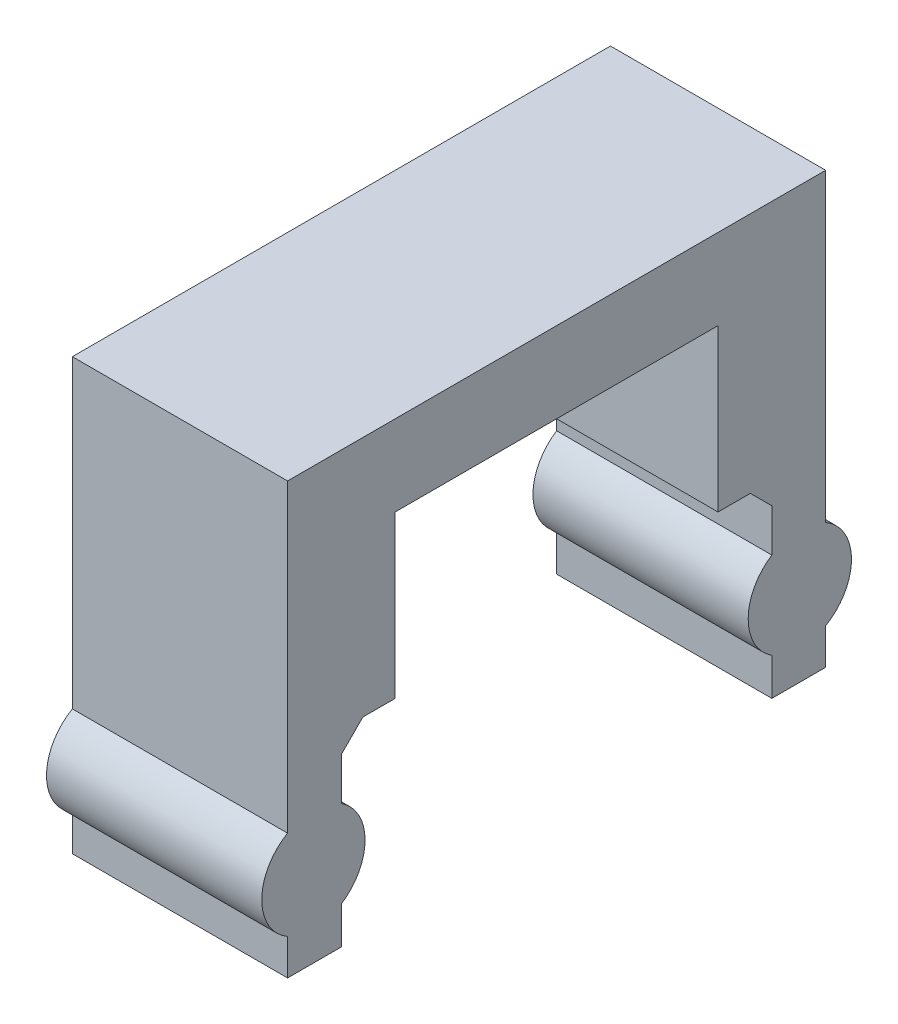
from build123d import *

# Parameters (mm, degrees)
BOSS_EXTRUDE1_DEPTH = 25.4
SKETCH4_R           = 6.096
BOSS_EXTRUDE2_DEPTH = 25.4
CHAMFER1_SIZE       = 2.54


with BuildPart() as part:
    # Sketch3 → Boss-Extrude1 (new body)
    with BuildSketch(Plane(origin=(0, 0, 0), x_dir=(0, 0, -1), z_dir=(1, 0, 0))):
        Polygon((-101.845577666, -12.277652747), (-95.495577666, -12.277652747), (-95.495577666, 9.947347253), (-89.145577666, 9.947347253), (-89.145577666, 28.997347253), (-51.045577666, 28.997347253), (-51.045577666, 9.947347253), (-44.695577666, 9.947347253), (-44.695577666, -12.277652747), (-38.345577666, -12.277652747), (-38.345577666, 38.522347253), (-101.845577666, 38.522347253), align=None)
    extrude(amount=BOSS_EXTRUDE1_DEPTH)

    # Sketch4 → Boss-Extrude2 (add)
    with BuildSketch(Plane(origin=(25.4, 0, 0), x_dir=(0, 0, -1), z_dir=(1, 0, 0))):
        with Locations((-98.797577666, -2.752652747)):
            Circle(SKETCH4_R)
        with Locations((-41.393577666, -2.752652747)):
            Circle(SKETCH4_R)
    extrude(amount=-BOSS_EXTRUDE2_DEPTH)

    # Chamfer1
    chamfer1_edges = [part.edges().sort_by_distance(p)[0] for p in [
        (12.7, 9.947347253, 44.695577666),
        (12.7, 9.947347253, 95.495577666),
    ]]
    chamfer(chamfer1_edges, length=CHAMFER1_SIZE)


solid = part.part
